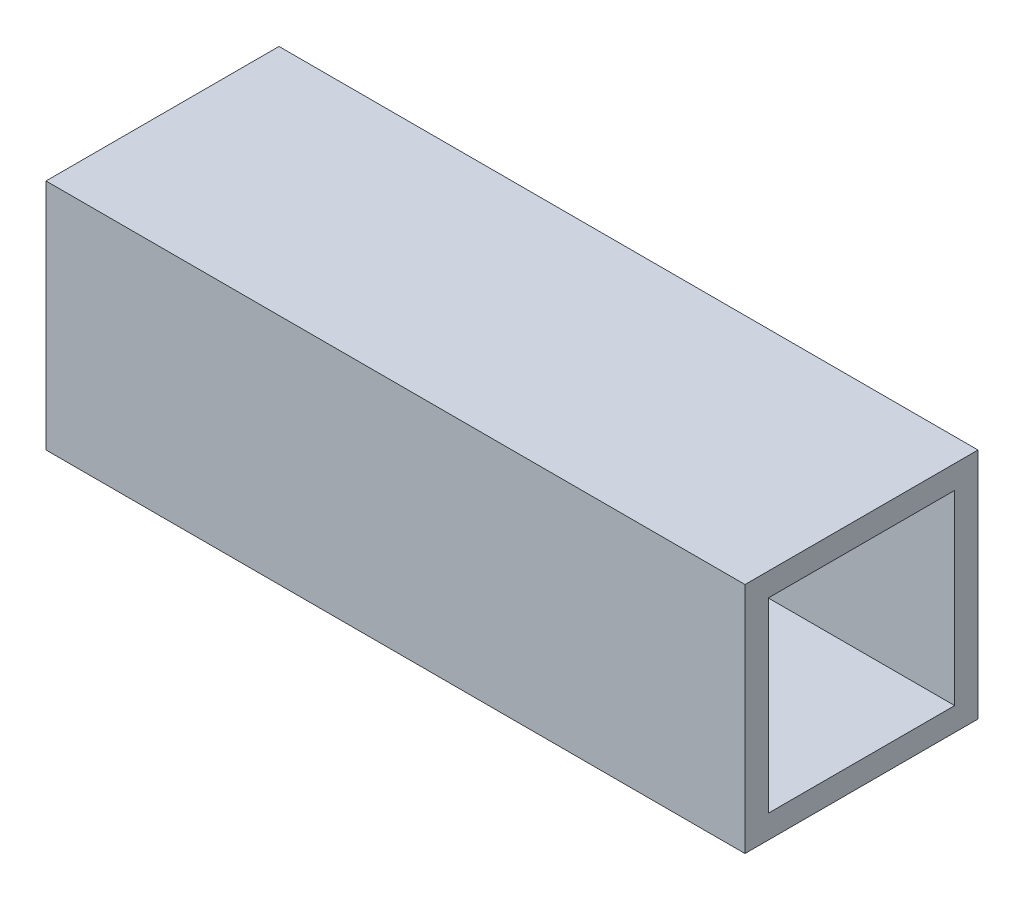
from build123d import *

# Parameters (mm, degrees)
SKETCH1_W           = 15
SKETCH1_H           = 15
SKETCH1_W_2         = 12
SKETCH1_H_2         = 12
BOSS_EXTRUDE1_DEPTH = 45


with BuildPart() as part:
    # Sketch1 → Boss-Extrude1 (new body)
    with BuildSketch(Plane(origin=(0, 0, 0), x_dir=(0, 0, -1), z_dir=(1, 0, 0))):
        Rectangle(SKETCH1_W, SKETCH1_H)
        Rectangle(SKETCH1_W_2, SKETCH1_H_2, mode=Mode.SUBTRACT)
    extrude(amount=BOSS_EXTRUDE1_DEPTH)


solid = part.part
